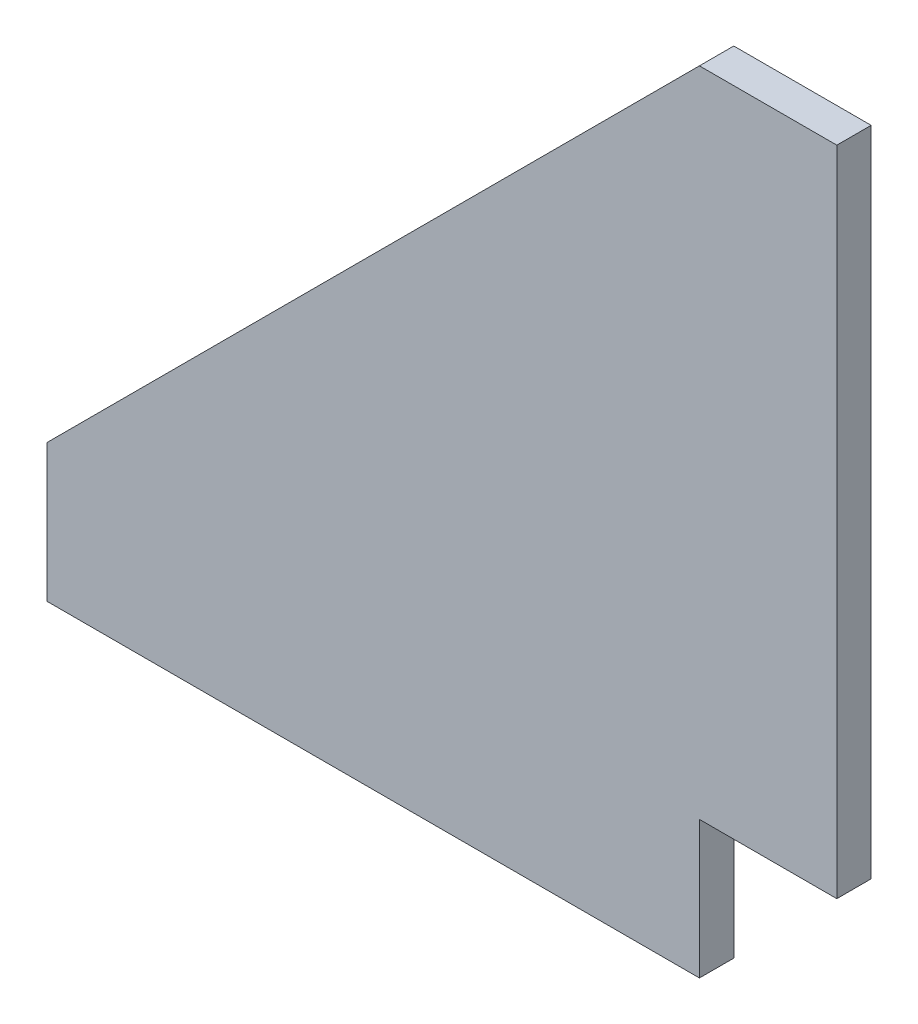
from build123d import *

# Parameters (mm, degrees)
BOSS_EXTRUDE1_DEPTH = 6.35


with BuildPart() as part:
    # Sketch1 → Boss-Extrude1 (new body)
    with BuildSketch(Plane.XY):
        Polygon((0, 0), (120.65, 0), (120.65, 25.4), (146.05, 25.4), (146.05, 146.05), (120.65, 146.05), (0, 25.4), align=None)
    extrude(amount=BOSS_EXTRUDE1_DEPTH)


solid = part.part
